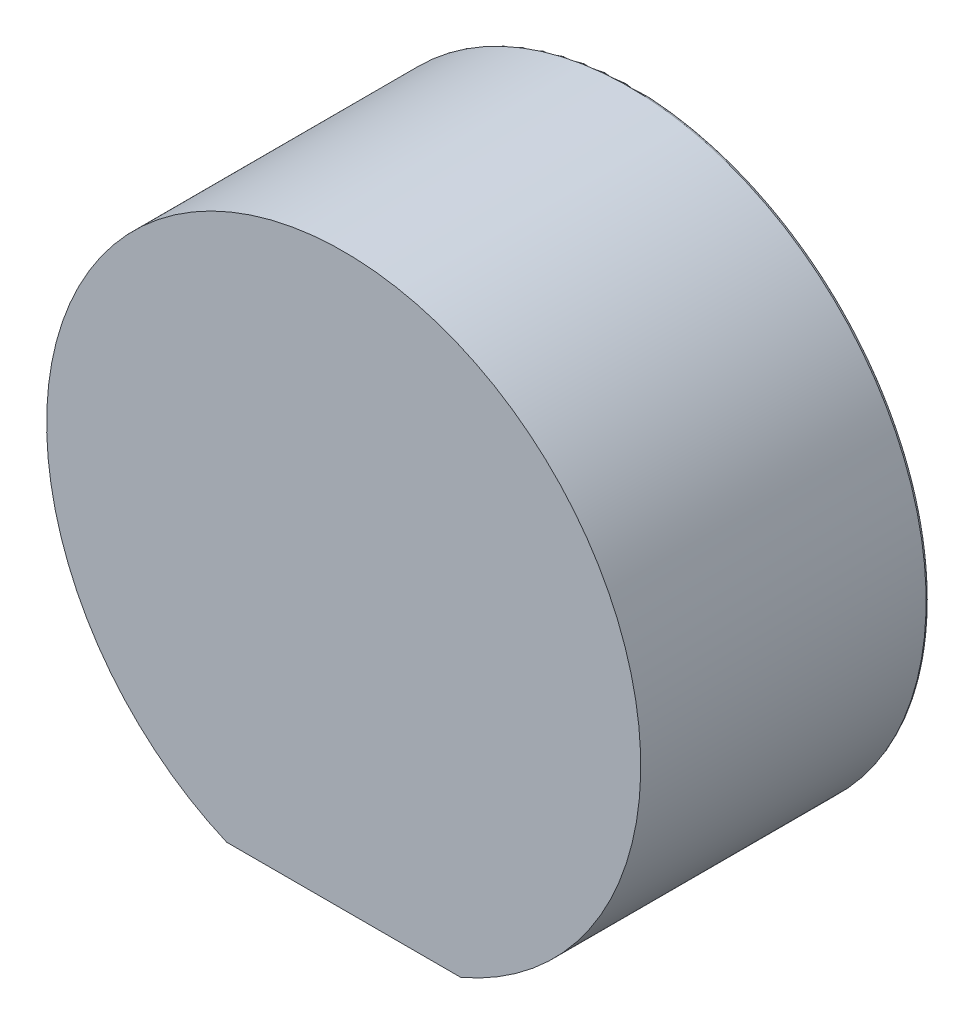
from build123d import *

# Parameters (mm, degrees)
BOSS_EXTRUDE1_DEPTH = 8
SKETCH7_R           = 16.5
BOSS_EXTRUDE2_DEPTH = 8
FILLET1_R           = 0.15


with BuildPart() as part:
    # Sketch1 → Boss-Extrude1 (new body)
    with BuildSketch(Plane.XY):
        with BuildLine():
            Line((-6.5, -15.165750888), (6.5, -15.165750888))
            ThreePointArc((6.5, -15.165750888), (0, 16.5), (-6.5, -15.165750888))
        make_face()
    extrude(amount=-BOSS_EXTRUDE1_DEPTH)

    # Sketch7 → Boss-Extrude2 (add)
    with BuildSketch(Plane(origin=(0, 0, -8), x_dir=(-1, 0, 0), z_dir=(0, 0, -1))):
        Circle(SKETCH7_R)
    extrude(amount=BOSS_EXTRUDE2_DEPTH)

    # Fillet1
    fillet1_edges = [part.edges().sort_by_distance(p)[0] for p in [
        (16.5, 0, -16),
    ]]
    fillet(fillet1_edges, radius=FILLET1_R)


solid = part.part
